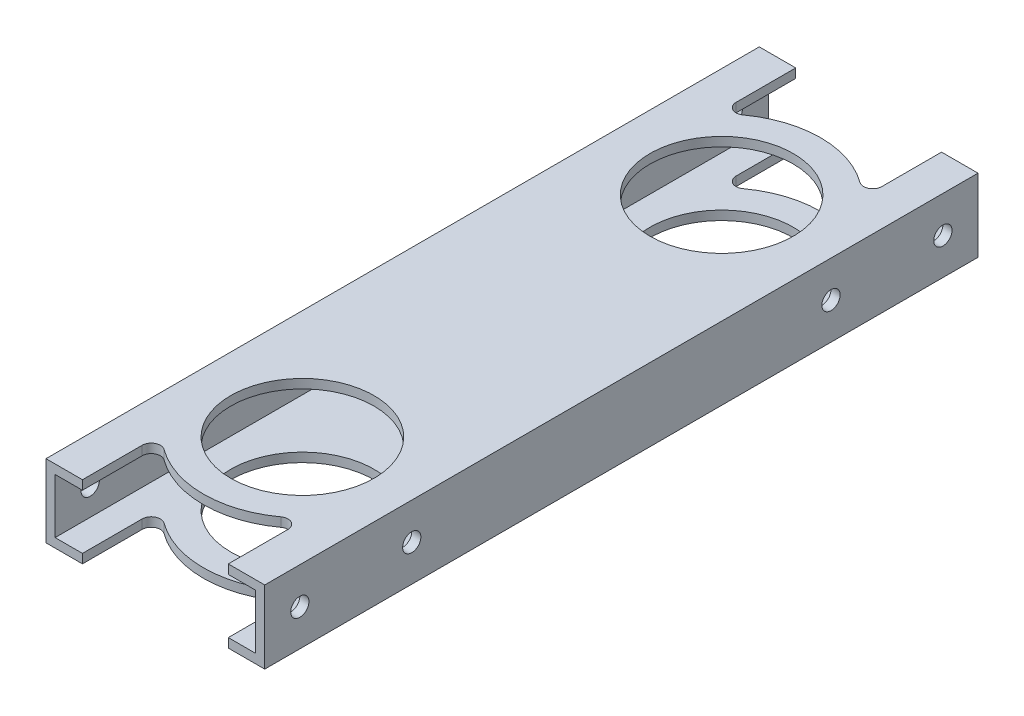
from build123d import *

# Parameters (mm, degrees)
SKETCH1_W           = 76.2
SKETCH1_H           = 25.4
SKETCH1_W_2         = 69.85
SKETCH1_H_2         = 19.05
EXTRUDE_THIN1_DEPTH = 279.4
CUT_EXTRUDE2_DEPTH  = 26.4
SKETCH4_R           = 24.97201
CUT_EXTRUDE3_DEPTH  = 26.4
CUT_EXTRUDE7_DEPTH  = 26.4
SKETCH7_R           = 3.175
CUT_EXTRUDE8_DEPTH  = 77.2
SKETCH8_R           = 3.175
CUT_EXTRUDE9_DEPTH  = 77.2


with BuildPart() as part:
    # Sketch1 → Extrude-Thin1 (new body)
    with BuildSketch(Plane.XY):
        Rectangle(SKETCH1_W, SKETCH1_H)
        Rectangle(SKETCH1_W_2, SKETCH1_H_2, mode=Mode.SUBTRACT)
    extrude(amount=EXTRUDE_THIN1_DEPTH)

    # Sketch3 → Cut-Extrude2 (cut, through all)
    with BuildSketch(Plane(origin=(0, 12.7, 0), x_dir=(1, 0, 0), z_dir=(0, 1, 0))):
        with BuildLine():
            ThreePointArc((-29.73451, -279.4), (-29.157760237, -285.228044516), (-27.449884971, -290.83))
            ThreePointArc((-27.449884971, -290.83), (0, -309.13451), (27.449884971, -290.83))
            ThreePointArc((27.449884971, -290.83), (29.157760237, -285.228044516), (29.73451, -279.4))
            Line((29.73451, -279.4), (-29.73451, -279.4))
        make_face()
        with BuildLine():
            ThreePointArc((29.73451, -279.4), (0, -249.66549), (-29.73451, -279.4))
            Line((-29.73451, -279.4), (29.73451, -279.4))
        make_face()
        with BuildLine():
            ThreePointArc((-29.73451, 0), (-29.157760237, -5.828044516), (-27.449884971, -11.43))
            ThreePointArc((-27.449884971, -11.43), (0, -29.73451), (27.449884971, -11.43))
            ThreePointArc((27.449884971, -11.43), (29.157760237, -5.828044516), (29.73451, 0))
            Line((29.73451, 0), (-29.73451, 0))
        make_face()
        with BuildLine():
            ThreePointArc((29.73451, 0), (0, 29.73451), (-29.73451, 0))
            Line((-29.73451, 0), (29.73451, 0))
        make_face()
    extrude(amount=-CUT_EXTRUDE2_DEPTH, mode=Mode.SUBTRACT)

    # Sketch4 → Cut-Extrude3 (cut, through all)
    with BuildSketch(Plane(origin=(0, 12.7, 0), x_dir=(1, 0, 0), z_dir=(0, 1, 0))):
        with Locations((0, -212.725)):
            Circle(SKETCH4_R)
        with Locations((0, -66.675)):
            Circle(SKETCH4_R)
    extrude(amount=-CUT_EXTRUDE3_DEPTH, mode=Mode.SUBTRACT)

    # Sketch6 → Cut-Extrude7 (cut, through all)
    with BuildSketch(Plane(origin=(0, 12.7, 0), x_dir=(1, 0, 0), z_dir=(0, 1, 0))):
        with BuildLine():
            Line((-38.1, 0), (-38.1, -15.459013065))
            Line((-38.1, -15.459013065), (-25.4, -15.459013065))
            ThreePointArc((-25.4, -15.459013065), (-28.630382803, -8.027594003), (-29.73451, 0))
            Line((-29.73451, 0), (-38.1, 0))
        make_face()
        with BuildLine():
            ThreePointArc((25.4, -15.459013065), (0, -29.73451), (-25.4, -15.459013065))
            Line((-25.4, -15.459013065), (-25.4, -36.257411134))
            ThreePointArc((-25.4, -36.257411134), (-23.662611537, -39.088294047), (-20.351875232, -38.821007943))
            ThreePointArc((-20.351875232, -38.821007943), (0, -32.17799), (20.351875232, -38.821007943))
            ThreePointArc((20.351875232, -38.821007943), (23.662611537, -39.088294047), (25.4, -36.257411134))
            Line((25.4, -36.257411134), (25.4, -15.459013065))
        make_face()
        with BuildLine():
            ThreePointArc((29.73451, 0), (28.630382803, -8.027594003), (25.4, -15.459013065))
            Line((25.4, -15.459013065), (38.1, -15.459013065))
            Line((38.1, -15.459013065), (38.1, 0))
            Line((38.1, 0), (29.73451, 0))
        make_face()
    cut_extrude7 = extrude(amount=-CUT_EXTRUDE7_DEPTH, mode=Mode.SUBTRACT)

    # Sketch7 → Cut-Extrude8 (cut, through all)
    with BuildSketch(Plane(origin=(38.1, 0, 0), x_dir=(0, 0, -1), z_dir=(1, 0, 0))):
        with Locations((-27.686, 0)):
            Circle(SKETCH7_R)
    cut_extrude8 = extrude(amount=-CUT_EXTRUDE8_DEPTH, mode=Mode.SUBTRACT)

    # Mirror3: Cut-Extrude7, Cut-Extrude8 across plane
    add(cut_extrude7.mirror(Plane.XY.offset(139.7)), mode=Mode.SUBTRACT)
    add(cut_extrude8.mirror(Plane.XY.offset(139.7)), mode=Mode.SUBTRACT)

    # Sketch8 → Cut-Extrude9 (cut, through all)
    with BuildSketch(Plane(origin=(38.1, 0, 0), x_dir=(0, 0, -1), z_dir=(1, 0, 0))):
        with Locations((-66.675, 0)):
            Circle(SKETCH8_R)
        with Locations((-212.725, 0)):
            Circle(SKETCH8_R)
    extrude(amount=-CUT_EXTRUDE9_DEPTH, mode=Mode.SUBTRACT)


solid = part.part
